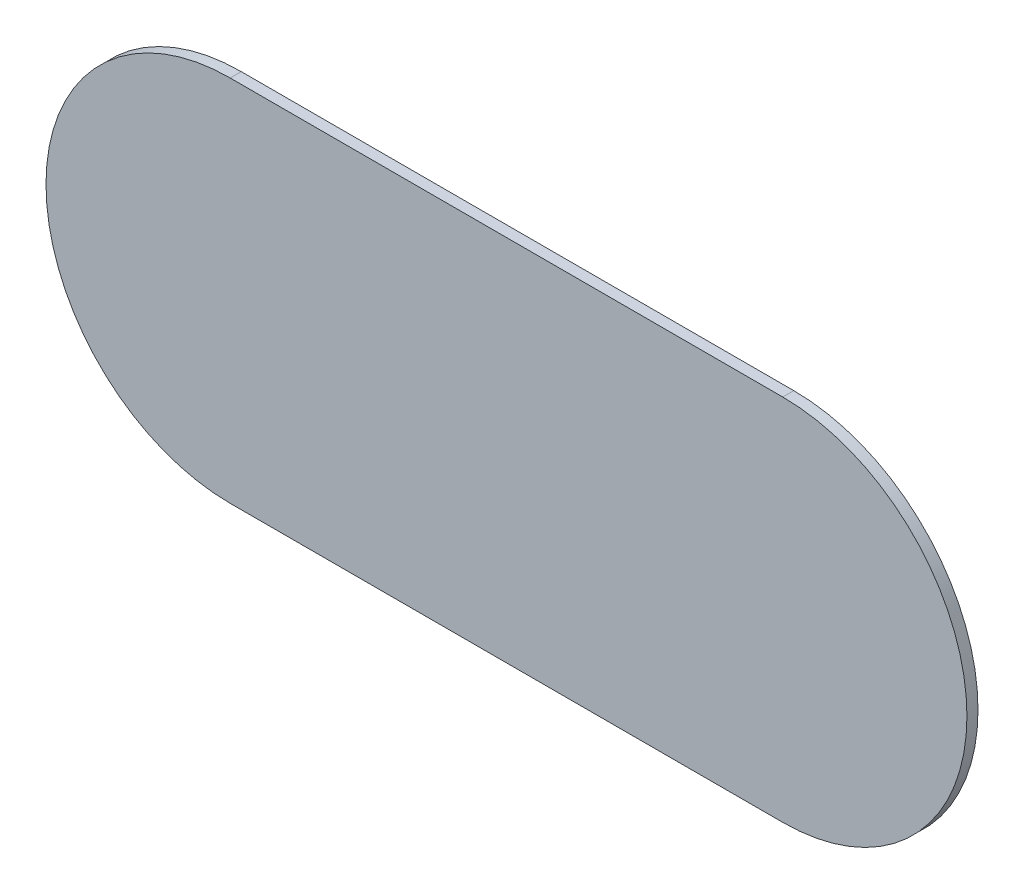
from build123d import *

# Parameters (mm, degrees)
BOSS_EXTRUDE1_DEPTH = 1.5


with BuildPart() as part:
    # Sketch1 → Boss-Extrude1 (new body)
    with BuildSketch(Plane.XY):
        with BuildLine():
            Line((70.992176204, 29.555648471), (145.992176204, 29.555648471))
            ThreePointArc((145.992176204, 29.555648471), (170.992176204, 4.555648471), (145.992176204, -20.444351529))
            Line((145.992176204, -20.444351529), (70.992176204, -20.444351529))
            ThreePointArc((70.992176204, -20.444351529), (45.992176204, 4.555648471), (70.992176204, 29.555648471))
        make_face()
    extrude(amount=BOSS_EXTRUDE1_DEPTH)


solid = part.part
